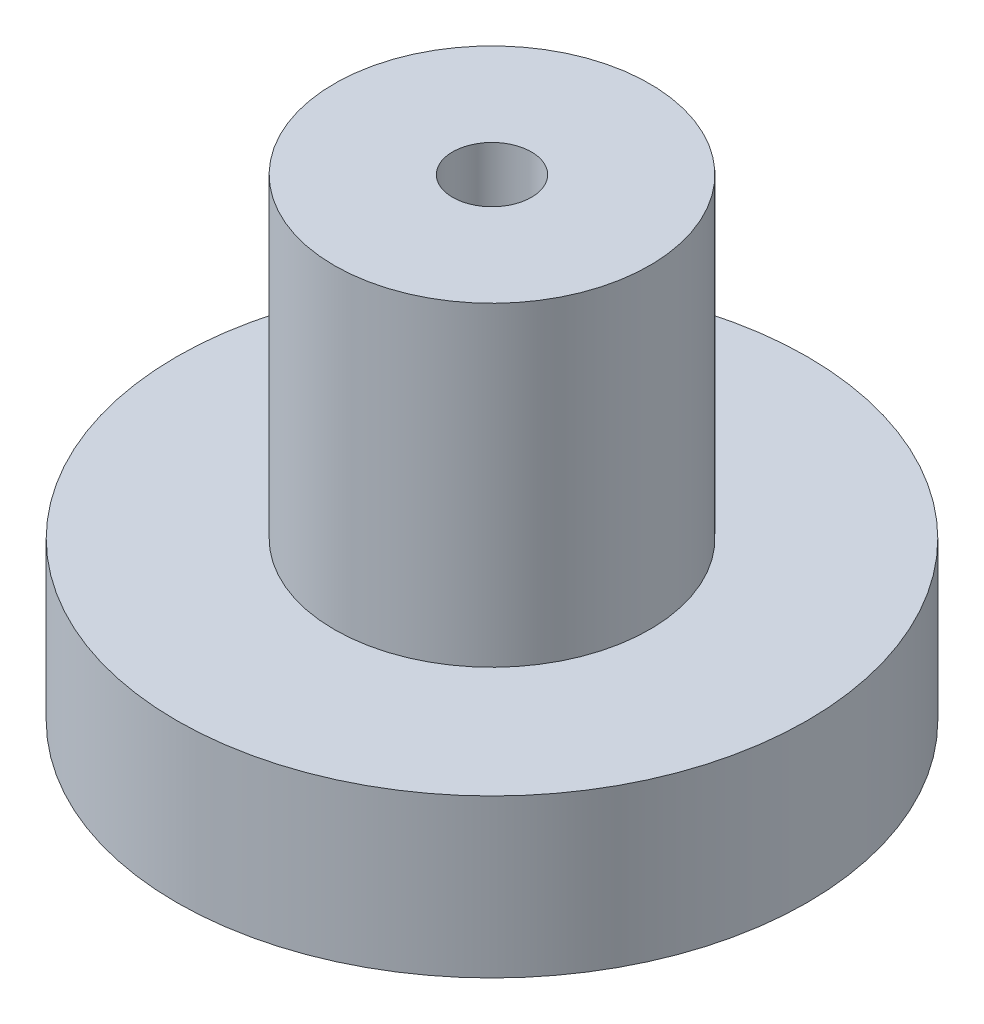
from build123d import *

# Parameters (mm, degrees)
SKETCH1_R           = 3.175
BOSS_EXTRUDE1_DEPTH = 4.7625
SKETCH2_R           = 3.175
SKETCH2_R_2         = 1.5875
CUT_EXTRUDE1_DEPTH  = 3.175
SKETCH3_R           = 0.396875
CUT_EXTRUDE2_DEPTH  = 5.7625


with BuildPart() as part:
    # Sketch1 → Boss-Extrude1 (new body)
    with BuildSketch(Plane(origin=(0, 0, 0), x_dir=(1, 0, 0), z_dir=(0, 1, 0))):
        Circle(SKETCH1_R)
    extrude(amount=BOSS_EXTRUDE1_DEPTH)

    # Sketch2 → Cut-Extrude1 (cut)
    with BuildSketch(Plane(origin=(0, 4.7625, 0), x_dir=(1, 0, 0), z_dir=(0, 1, 0))):
        Circle(SKETCH2_R)
        Circle(SKETCH2_R_2, mode=Mode.SUBTRACT)
    extrude(amount=-CUT_EXTRUDE1_DEPTH, mode=Mode.SUBTRACT)

    # Sketch3 → Cut-Extrude2 (cut, through all)
    with BuildSketch(Plane(origin=(0, 4.7625, 0), x_dir=(1, 0, 0), z_dir=(0, 1, 0))):
        Circle(SKETCH3_R)
    extrude(amount=-CUT_EXTRUDE2_DEPTH, mode=Mode.SUBTRACT)

    # Sketch4 → Cut-Revolve1 (revolve, cut)
    with BuildSketch(Plane(origin=(0, 0, 0), x_dir=(0, 0, -1), z_dir=(1, 0, 0))):
        Polygon((0, 0), (0, 0.79375), (-0.79375, 0), align=None)
    revolve(axis=Axis((0, 0, 0), (0, 1, 0)), mode=Mode.SUBTRACT)


solid = part.part
